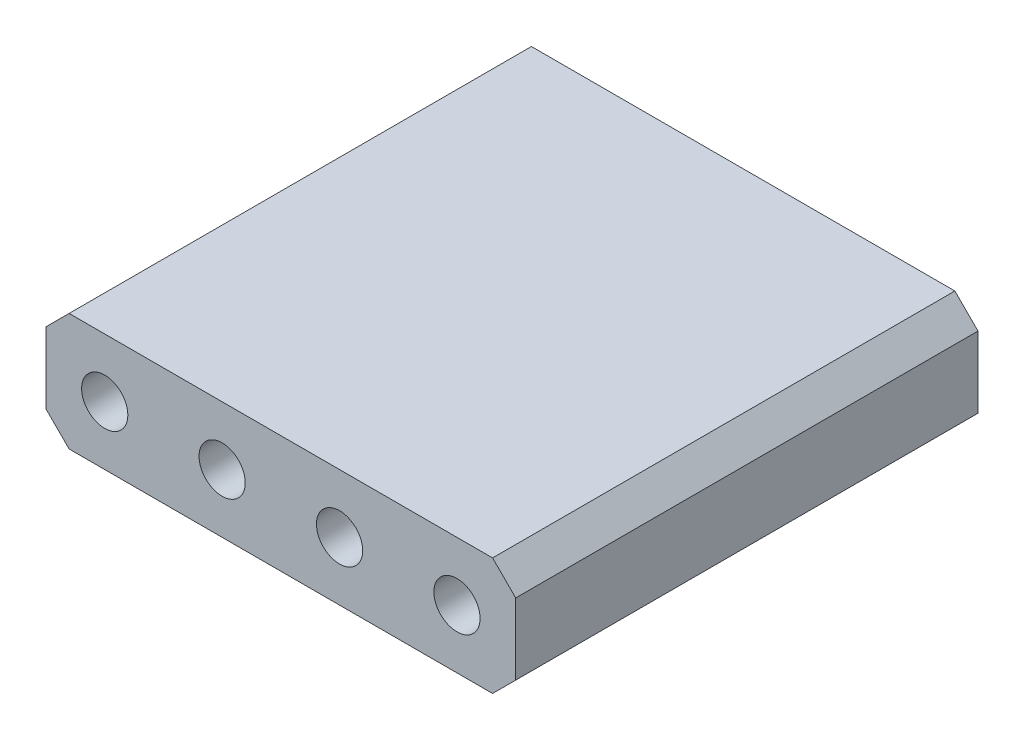
from build123d import *

# Parameters (mm, degrees)
SKETCH_2_W      = 10.16
SKETCH_2_H      = 2.54
SKETCH_2_R      = 0.5
EXTRUDE_1_DEPTH = 10
CHAMFER_2_SIZE  = 0.5


with BuildPart() as part:
    # Эскиз2 → Бобышка-Вытянуть1 (new body)
    with BuildSketch(Plane.XY):
        Rectangle(SKETCH_2_W, SKETCH_2_H)
        with Locations((-3.81, 0)):
            Circle(SKETCH_2_R, mode=Mode.SUBTRACT)
        with Locations((-1.27, 0)):
            Circle(SKETCH_2_R, mode=Mode.SUBTRACT)
        with Locations((1.27, 0)):
            Circle(SKETCH_2_R, mode=Mode.SUBTRACT)
        with Locations((3.81, 0)):
            Circle(SKETCH_2_R, mode=Mode.SUBTRACT)
    extrude(amount=EXTRUDE_1_DEPTH)

    # Фаска2
    chamfer_2_edges = [part.edges().sort_by_distance(p)[0] for p in [
        (5.08, -1.27, 5),
        (-5.08, -1.27, 5),
        (-5.08, 1.27, 5),
        (5.08, 1.27, 5),
    ]]
    chamfer(chamfer_2_edges, length=CHAMFER_2_SIZE)


solid = part.part
